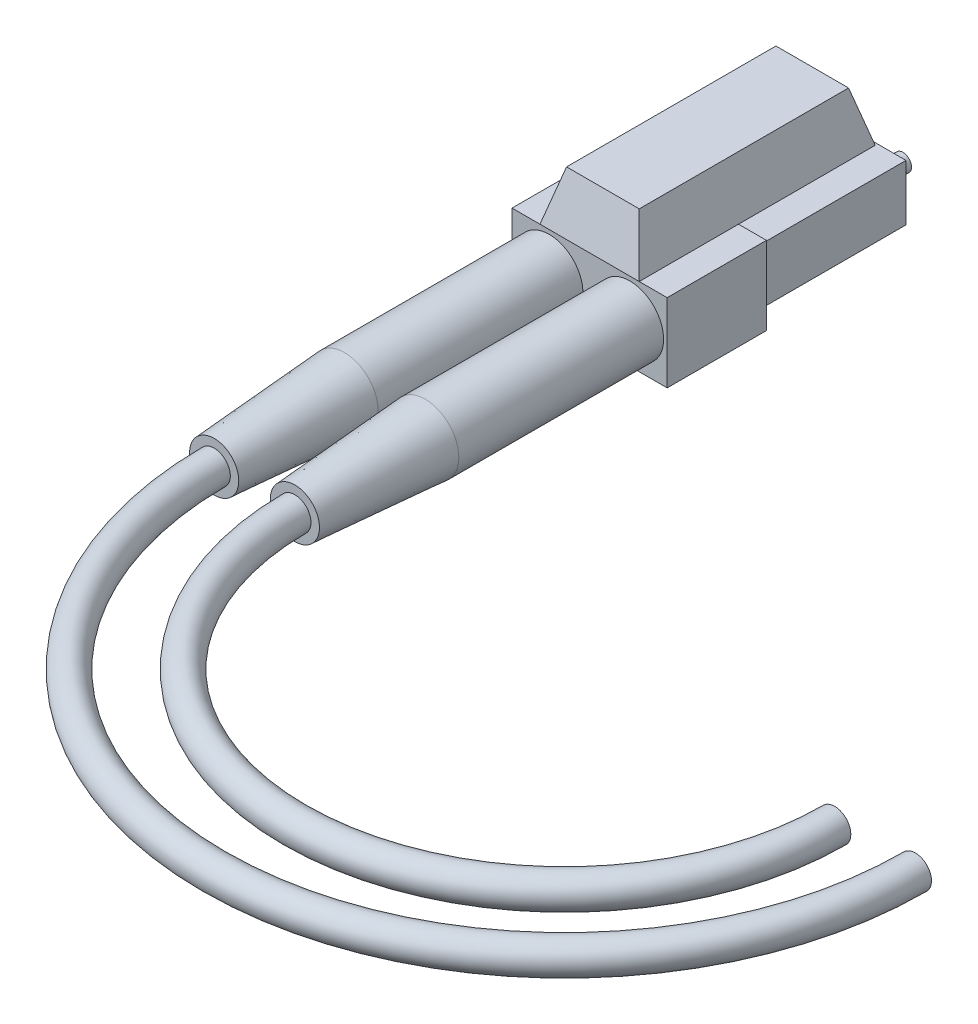
from build123d import *

# Parameters (mm, degrees)
SKETCH1_W             = 4.5
SKETCH1_H             = 4.5
BOSS_EXTRUDE1_DEPTH   = 12
BOSS_EXTRUDE1_2_DEPTH = 12
SKETCH2_R             = 0.691748062
BOSS_EXTRUDE2_DEPTH   = 2
SKETCH3_W             = 12.5
SKETCH3_H             = 6.3
BOSS_EXTRUDE3_DEPTH   = 8
SKETCH4_R             = 2.715
BOSS_EXTRUDE4_DEPTH   = 16.5
SKETCH5_R             = 2.715
BOSS_EXTRUDE5_DEPTH   = 10.5
BOSS_EXTRUDE5_TAPER   = 4
SKETCH8_W             = 8
SKETCH8_H             = 19.014368052
BOSS_EXTRUDE8_DEPTH   = 4
BOSS_EXTRUDE8_TAPER   = 15
PROFILE1_R            = 1.3


with BuildPart() as part:
    # Sketch1 → Boss-Extrude1 (new body)
    with BuildSketch(Plane.XY):
        with Locations((3.245938438, 2.25)):
            Rectangle(SKETCH1_W, SKETCH1_H)
    extrude(amount=-BOSS_EXTRUDE1_DEPTH)



with BuildPart() as body_2:
    # Sketch1 → Boss-Extrude1 2 (new body)
    with BuildSketch(Plane.XY):
        with Locations((-3.254061562, 2.25)):
            Rectangle(SKETCH1_W, SKETCH1_H)
    extrude(amount=-BOSS_EXTRUDE1_2_DEPTH)


with BuildPart() as part_1:
    add(part.part)

    add(body_2.part)  # Boss-Extrude2 merges body 2
    # Sketch2 → Boss-Extrude2 (add)
    with BuildSketch(Plane(origin=(0, 0, -12), x_dir=(-1, 0, 0), z_dir=(0, 0, -1))):
        with Locations((3.25, 2.25)):
            Circle(SKETCH2_R)
        with Locations((-3.25, 2.25)):
            Circle(SKETCH2_R)
    extrude(amount=BOSS_EXTRUDE2_DEPTH)

    # Sketch3 → Boss-Extrude3 (add)
    with BuildSketch(Plane.XY):
        with Locations((0, 2.15)):
            Rectangle(SKETCH3_W, SKETCH3_H)
    extrude(amount=BOSS_EXTRUDE3_DEPTH)

    # Sketch4 → Boss-Extrude4 (add)
    with BuildSketch(Plane.XY.offset(8)):
        with Locations((3.25, 2.25)):
            Circle(SKETCH4_R)
        with Locations((-3.25, 2.25)):
            Circle(SKETCH4_R)
    extrude(amount=BOSS_EXTRUDE4_DEPTH)

    # Sketch5 → Boss-Extrude5 (add)
    with BuildSketch(Plane.XY.offset(24.5)):
        with Locations((-3.25, 2.25)):
            Circle(SKETCH5_R)
        with Locations((3.25, 2.25)):
            Circle(SKETCH5_R)
    extrude(amount=BOSS_EXTRUDE5_DEPTH, taper=BOSS_EXTRUDE5_TAPER)

    # Sketch8 → Boss-Extrude8 (add)
    with BuildSketch(Plane(origin=(0, 5.3, 0), x_dir=(1, 0, 0), z_dir=(0, 1, 0))):
        with Locations((0, 1.507184026)):
            Rectangle(SKETCH8_W, SKETCH8_H)
    extrude(amount=BOSS_EXTRUDE8_DEPTH, taper=BOSS_EXTRUDE8_TAPER)

    # Sweep1: sweep along a path in path1
    with BuildLine(Plane.XZ.offset(-2.25)) as sweep1_path:
        ThreePointArc((0, 35), (25, 60), (50, 35))
    # profile1 → Sweep1 (sweep)
    with BuildSketch(Plane.XY.offset(35)):
        with Locations((-3.25, 2.25)):
            Circle(PROFILE1_R)
        with Locations((3.25, 2.25)):
            Circle(PROFILE1_R)
    sweep(path=sweep1_path.line)


solid = part_1.part
